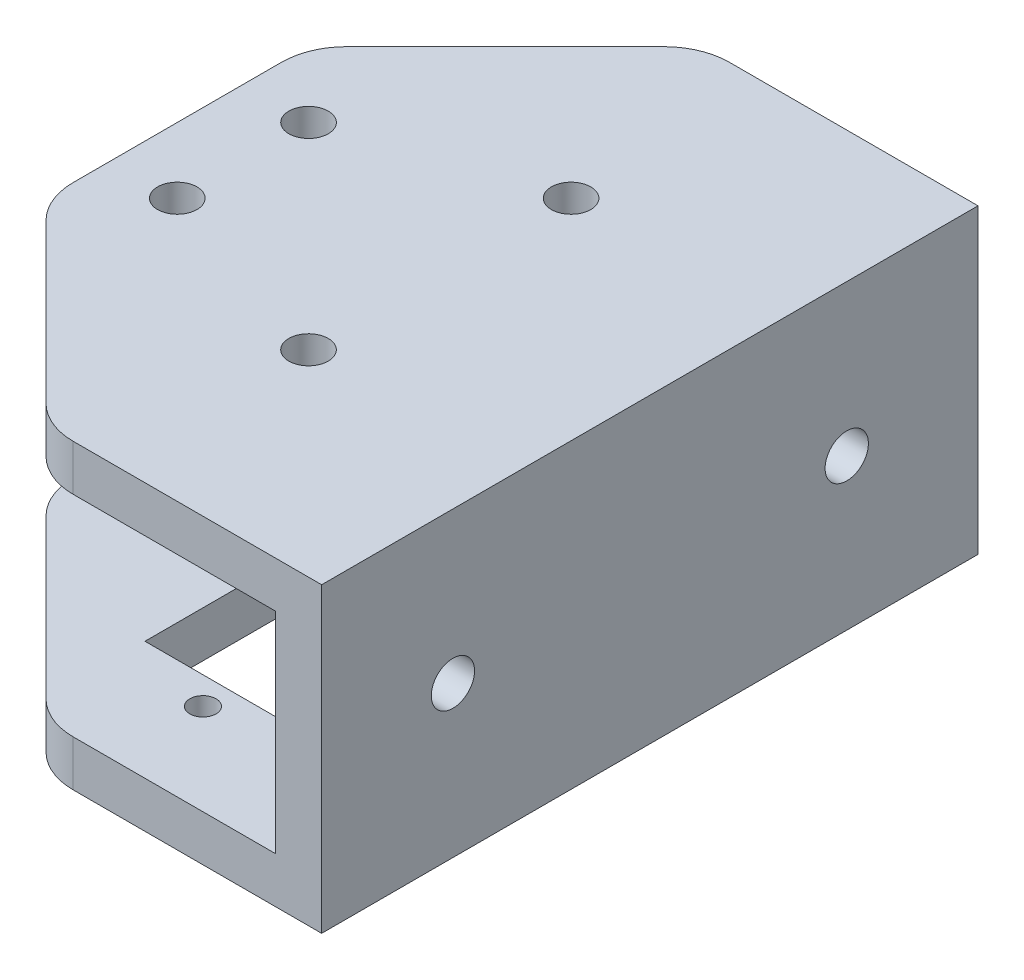
from build123d import *

# Parameters (mm, degrees)
EXTRUDE_1_DEPTH     = 50
CUT_EXTRUDE_START   = -19.5
SKETCH_2_R          = 1.5
CUT_EXTRUDE_1_DEPTH = 70
SKETCH_3_OUTSIDE_W  = 61.218
SKETCH_3_OUTSIDE_H  = 66.218
CUT_EXTRUDE_2_DEPTH = 70
SKETCH_2_3_R        = 1.5
CUT_EXTRUDE_4_DEPTH = 10
SKETCH_5_R          = 1
CUT_EXTRUDE_5_DEPTH = 10
FILLET_1_R          = 5
SKETCH_6_W          = 13
SKETCH_6_H          = 23.5
CUT_EXTRUDE_6_DEPTH = 10
SKETCH_7_R          = 1.65
CUT_EXTRUDE_7_DEPTH = 10


with BuildPart() as part:
    # Sketch 1 → Extrude 1 (new body)
    with BuildSketch(Plane.XY):
        Polygon((-45, 11.5), (0, 11.5), (0, -11.5), (-45, -11.5), (-45, -8), (-3.5, -8), (-3.5, 8), (-45, 8), align=None)
    extrude(amount=EXTRUDE_1_DEPTH)

    # Sketch 2 → Cut-Extrude 1 (cut)
    with BuildSketch(Plane.XZ.offset(11.5).offset(CUT_EXTRUDE_START)):
        with Locations((-16, 35)):
            Circle(SKETCH_2_R)
        with Locations((-16, 15)):
            Circle(SKETCH_2_R)
        with Locations((-31, 30)):
            Circle(SKETCH_2_R)
        with Locations((-31, 20)):
            Circle(SKETCH_2_R)
    extrude(amount=-CUT_EXTRUDE_1_DEPTH, mode=Mode.SUBTRACT)

    # Sketch 3 outside → Cut-Extrude 2 (cut)
    with BuildSketch(Plane.XZ.offset(11.5)):
        with Locations((-22.5, 25)):
            Rectangle(SKETCH_3_OUTSIDE_W, SKETCH_3_OUTSIDE_H)
        Polygon((-21, 0), (-36, 15), (-36, 35), (-21, 50), (0, 50), (0, 0), align=None, mode=Mode.SUBTRACT)
    extrude(amount=-CUT_EXTRUDE_2_DEPTH, mode=Mode.SUBTRACT)

    # Sketch 2_3 → Cut-Extrude 4 (cut)
    with BuildSketch(Plane.XZ.offset(11.5)):
        with Locations((-31, 30)):
            Circle(SKETCH_2_3_R)
        with Locations((-31, 20)):
            Circle(SKETCH_2_3_R)
    extrude(amount=-CUT_EXTRUDE_4_DEPTH, mode=Mode.SUBTRACT)

    # Sketch 5 → Cut-Extrude 5 (cut)
    with BuildSketch(Plane.XZ.offset(11.5)):
        with Locations((-16, 43.045)):
            Circle(SKETCH_5_R)
        with Locations((-16, 15.375)):
            Circle(SKETCH_5_R)
    extrude(amount=-CUT_EXTRUDE_5_DEPTH, mode=Mode.SUBTRACT)

    # Fillet 1
    fillet_1_edges = [part.edges().sort_by_distance(p)[0] for p in [
        (-21, -9.75, 0),
        (-21, 9.75, 0),
        (-21, -9.75, 50),
        (-21, 9.75, 50),
        (-36, 9.75, 35),
        (-36, -9.75, 35),
        (-36, 9.75, 15),
        (-36, -9.75, 15),
    ]]
    fillet(fillet_1_edges, radius=FILLET_1_R)

    # Sketch 6 → Cut-Extrude 6 (cut)
    with BuildSketch(Plane.XZ.offset(11.5)):
        with Locations((-16, 29.21)):
            Rectangle(SKETCH_6_W, SKETCH_6_H)
    extrude(amount=-CUT_EXTRUDE_6_DEPTH, mode=Mode.SUBTRACT)

    # Sketch 7 → Cut-Extrude 7 (cut)
    with BuildSketch(Plane(origin=(0, 0, 0), x_dir=(0, 0, -1), z_dir=(1, 0, 0))):
        with Locations((-10, 0)):
            Circle(SKETCH_7_R)
        with Locations((-40, 0)):
            Circle(SKETCH_7_R)
    extrude(amount=-CUT_EXTRUDE_7_DEPTH, mode=Mode.SUBTRACT)


solid = part.part
